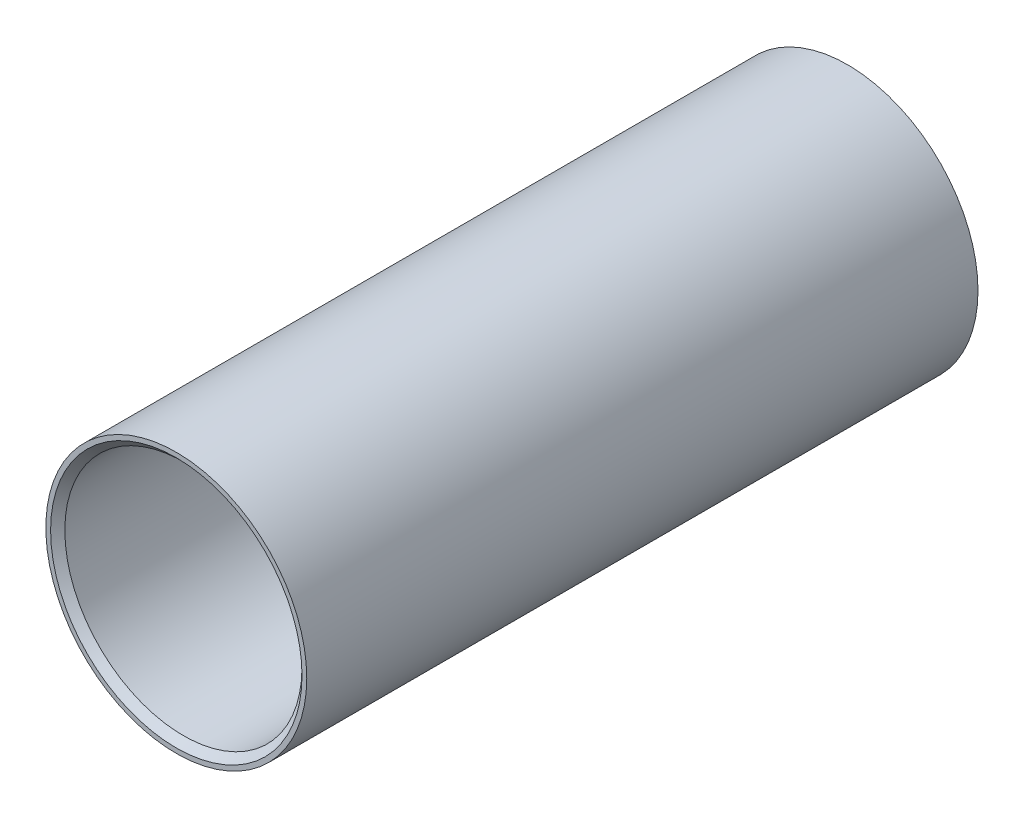
from build123d import *


with BuildPart() as part:
    # Sketch1 → Revolve1 (revolve)
    with BuildSketch(Plane(origin=(0, 0, 0), x_dir=(0, 0, -1), z_dir=(1, 0, 0))):
        Polygon((-14.15, 5.5), (14.15, 5.5), (14.15, 5.3), (13.85, 5), (-13.85, 5), (-14.15, 5.3), align=None)
    revolve(axis=Axis((0, 0, 0), (0, 0, -1)))


solid = part.part
